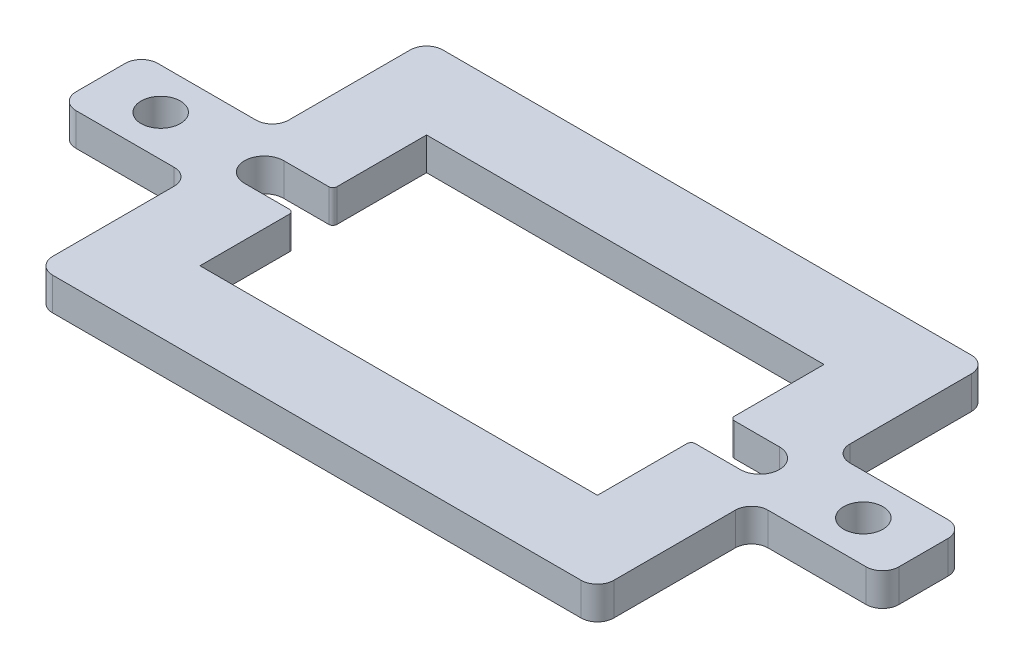
from build123d import *

# Parameters (mm, degrees)
SKETCH1_W            = 34.3
SKETCH1_H            = 23.85
SKETCH1_W_2          = 24.3
SKETCH1_H_2          = 13.85
BOSS_EXTRUDE1_DEPTH  = 2
SKETCH4_W            = 8
SKETCH4_H            = 5
BOSS_EXTRUDE2_DEPTH  = 2
M2_CLEARANCE_HOLE1_D = 2.4
FILLET1_R            = 1
CUT_EXTRUDE1_DEPTH   = 3
FILLET2_R            = 0.25


with BuildPart() as part:
    # Sketch1 → Boss-Extrude1 (new body)
    with BuildSketch(Plane(origin=(0, 0, 0), x_dir=(1, 0, 0), z_dir=(0, 1, 0))):
        Rectangle(SKETCH1_W, SKETCH1_H)
        Rectangle(SKETCH1_W_2, SKETCH1_H_2, mode=Mode.SUBTRACT)
    extrude(amount=BOSS_EXTRUDE1_DEPTH)

    # Sketch4 → Boss-Extrude2 (add)
    with BuildSketch(Plane(origin=(0, 2, 0), x_dir=(1, 0, 0), z_dir=(0, 1, 0))):
        with Locations((-21.15, 0)):
            Rectangle(SKETCH4_W, SKETCH4_H)
        with Locations((21.15, 0)):
            Rectangle(SKETCH4_W, SKETCH4_H)
    extrude(amount=-BOSS_EXTRUDE2_DEPTH)

    # M2 Clearance Hole1 (through all)
    with Locations(Plane(origin=(0, 2, 0), x_dir=(1, 0, 0), z_dir=(0, 1, 0))):
        with Locations((-13.975, 0), (13.975, 0), (-21.475, 0), (21.475, 0)):
            Hole(M2_CLEARANCE_HOLE1_D / 2)

    # Fillet1
    fillet1_edges = [part.edges().sort_by_distance(p)[0] for p in [
        (-17.15, 1, -2.5),
        (-17.15, 1, 2.5),
        (-25.15, 1, 2.5),
        (-25.15, 1, -2.5),
        (17.15, 1, 2.5),
        (17.15, 1, -2.5),
        (25.15, 1, -2.5),
        (25.15, 1, 2.5),
        (-17.15, 1, -11.925),
        (17.15, 1, -11.925),
        (17.15, 1, 11.925),
        (-17.15, 1, 11.925),
    ]]
    fillet(fillet1_edges, radius=FILLET1_R)

    # Sketch5 → Cut-Extrude1 (cut, through all)
    with BuildSketch(Plane(origin=(0, 2, 0), x_dir=(1, 0, 0), z_dir=(0, 1, 0))):
        with BuildLine():
            Line((-12.15, 1.2), (-15.15, 1.2))
            ThreePointArc((-15.15, 1.2), (-16.35, 0), (-15.15, -1.2))
            Line((-15.15, -1.2), (-12.15, -1.2))
            Line((-12.15, -1.2), (-12.15, 1.2))
        make_face()
        with BuildLine():
            Line((12.15, 1.2), (15.15, 1.2))
            ThreePointArc((15.15, 1.2), (16.35, 0), (15.15, -1.2))
            Line((15.15, -1.2), (12.15, -1.2))
            Line((12.15, -1.2), (12.15, 1.2))
        make_face()
    extrude(amount=-CUT_EXTRUDE1_DEPTH, mode=Mode.SUBTRACT)

    # Fillet2
    fillet2_edges = [part.edges().sort_by_distance(p)[0] for p in [
        (-12.15, 1, 1.2),
        (-12.15, 1, -1.2),
        (12.15, 1, -1.2),
        (12.15, 1, 1.2),
    ]]
    fillet(fillet2_edges, radius=FILLET2_R)


solid = part.part
